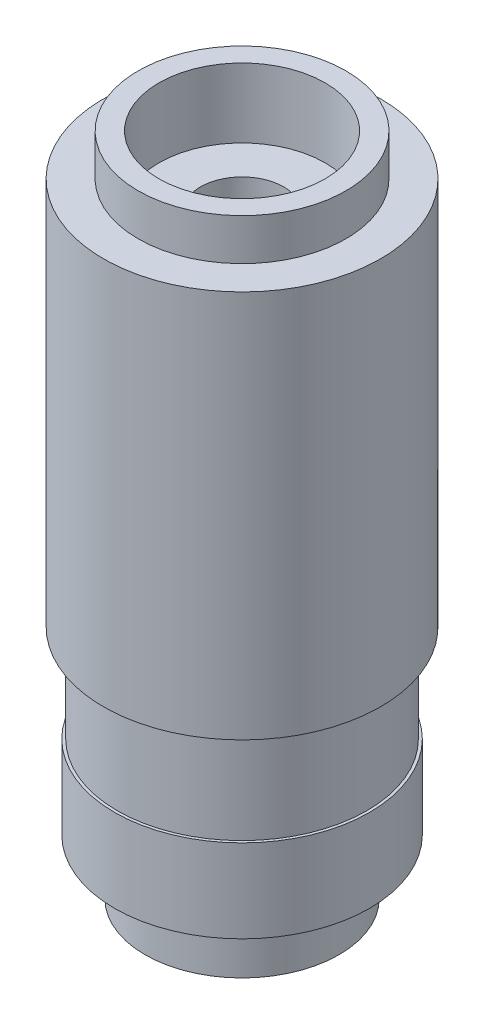
from build123d import *

# Parameters (mm, degrees)
CUT_EXTRUDE_1_DEPTH = 3


with BuildPart() as part:
    # Эскиз1 → Повернуть1 (revolve)
    with BuildSketch(Plane.XY):
        Polygon((3.5, 0), (1.8, 0), (1.8, 4), (1.5, 4.292679061), (1.5, 21.5), (3, 21.5), (3, 24), (3.75, 24), (3.75, 22.5), (5, 22.5), (5, 8.5), (4.5, 8.5), (4.5, 5), (4.6, 5), (4.6, 2), (3.5, 2), align=None)
    revolve(axis=Axis((0, 0, 0), (0, 1, 0)))

    # Эскиз3 → Вырез-Вытянуть1 (cut)
    with BuildSketch(Plane.XZ):
        with BuildLine():
            Line((0.046977339, 1.799386876), (0.31286893, 1.975376681))
            Line((0.31286893, 1.975376681), (0.51136302, 1.72583541))
            ThreePointArc((0.51136302, 1.72583541), (0.55623059, 1.711901729), (0.600719228, 1.696801818))
            Line((0.600719228, 1.696801818), (0.907980999, 1.782013048))
            Line((0.907980999, 1.782013048), (1.019647604, 1.483347149))
            ThreePointArc((1.019647604, 1.483347149), (1.058013454, 1.45623059), (1.095658534, 1.428121975))
            Line((1.095658534, 1.428121975), (1.414213562, 1.414213562))
            Line((1.414213562, 1.414213562), (1.428121975, 1.095658534))
            ThreePointArc((1.428121975, 1.095658534), (1.45623059, 1.058013454), (1.483347149, 1.019647604))
            Line((1.483347149, 1.019647604), (1.782013048, 0.907980999))
            Line((1.782013048, 0.907980999), (1.696801818, 0.600719228))
            ThreePointArc((1.696801818, 0.600719228), (1.711901729, 0.55623059), (1.72583541, 0.51136302))
            Line((1.72583541, 0.51136302), (1.975376681, 0.31286893))
            Line((1.975376681, 0.31286893), (1.799386876, 0.046977339))
            ThreePointArc((1.799386876, 0.046977339), (1.8, 0), (1.799386876, -0.046977339))
            Line((1.799386876, -0.046977339), (1.975376681, -0.31286893))
            Line((1.975376681, -0.31286893), (1.72583541, -0.51136302))
            ThreePointArc((1.72583541, -0.51136302), (1.711901729, -0.55623059), (1.696801818, -0.600719228))
            Line((1.696801818, -0.600719228), (1.782013048, -0.907980999))
            Line((1.782013048, -0.907980999), (1.483347149, -1.019647604))
            ThreePointArc((1.483347149, -1.019647604), (1.45623059, -1.058013454), (1.428121975, -1.095658534))
            Line((1.428121975, -1.095658534), (1.414213562, -1.414213562))
            Line((1.414213562, -1.414213562), (1.095658534, -1.428121975))
            ThreePointArc((1.095658534, -1.428121975), (1.058013454, -1.45623059), (1.019647604, -1.483347149))
            Line((1.019647604, -1.483347149), (0.907980999, -1.782013048))
            Line((0.907980999, -1.782013048), (0.600719228, -1.696801818))
            ThreePointArc((0.600719228, -1.696801818), (0.55623059, -1.711901729), (0.51136302, -1.72583541))
            Line((0.51136302, -1.72583541), (0.31286893, -1.975376681))
            Line((0.31286893, -1.975376681), (0.046977339, -1.799386876))
            ThreePointArc((0.046977339, -1.799386876), (0, -1.8), (-0.046977339, -1.799386876))
            Line((-0.046977339, -1.799386876), (-0.31286893, -1.975376681))
            Line((-0.31286893, -1.975376681), (-0.51136302, -1.72583541))
            ThreePointArc((-0.51136302, -1.72583541), (-0.55623059, -1.711901729), (-0.600719228, -1.696801818))
            Line((-0.600719228, -1.696801818), (-0.907980999, -1.782013048))
            Line((-0.907980999, -1.782013048), (-1.019647604, -1.483347149))
            ThreePointArc((-1.019647604, -1.483347149), (-1.058013454, -1.45623059), (-1.095658534, -1.428121975))
            Line((-1.095658534, -1.428121975), (-1.414213562, -1.414213562))
            Line((-1.414213562, -1.414213562), (-1.428121975, -1.095658534))
            ThreePointArc((-1.428121975, -1.095658534), (-1.45623059, -1.058013454), (-1.483347149, -1.019647604))
            Line((-1.483347149, -1.019647604), (-1.782013048, -0.907980999))
            Line((-1.782013048, -0.907980999), (-1.696801818, -0.600719228))
            ThreePointArc((-1.696801818, -0.600719228), (-1.711901729, -0.55623059), (-1.72583541, -0.51136302))
            Line((-1.72583541, -0.51136302), (-1.975376681, -0.31286893))
            Line((-1.975376681, -0.31286893), (-1.799386876, -0.046977339))
            ThreePointArc((-1.799386876, -0.046977339), (-1.8, 0), (-1.799386876, 0.046977339))
            Line((-1.799386876, 0.046977339), (-1.975376681, 0.31286893))
            Line((-1.975376681, 0.31286893), (-1.72583541, 0.51136302))
            ThreePointArc((-1.72583541, 0.51136302), (-1.711901729, 0.55623059), (-1.696801818, 0.600719228))
            Line((-1.696801818, 0.600719228), (-1.782013048, 0.907980999))
            Line((-1.782013048, 0.907980999), (-1.483347149, 1.019647604))
            ThreePointArc((-1.483347149, 1.019647604), (-1.45623059, 1.058013454), (-1.428121975, 1.095658534))
            Line((-1.428121975, 1.095658534), (-1.414213562, 1.414213562))
            Line((-1.414213562, 1.414213562), (-1.095658534, 1.428121975))
            ThreePointArc((-1.095658534, 1.428121975), (-1.058013454, 1.45623059), (-1.019647604, 1.483347149))
            Line((-1.019647604, 1.483347149), (-0.907980999, 1.782013048))
            Line((-0.907980999, 1.782013048), (-0.600719228, 1.696801818))
            ThreePointArc((-0.600719228, 1.696801818), (-0.55623059, 1.711901729), (-0.51136302, 1.72583541))
            Line((-0.51136302, 1.72583541), (-0.31286893, 1.975376681))
            Line((-0.31286893, 1.975376681), (-0.046977339, 1.799386876))
            ThreePointArc((-0.046977339, 1.799386876), (0, 1.8), (0.046977339, 1.799386876))
        make_face()
    extrude(amount=-CUT_EXTRUDE_1_DEPTH, mode=Mode.SUBTRACT)


solid = part.part
